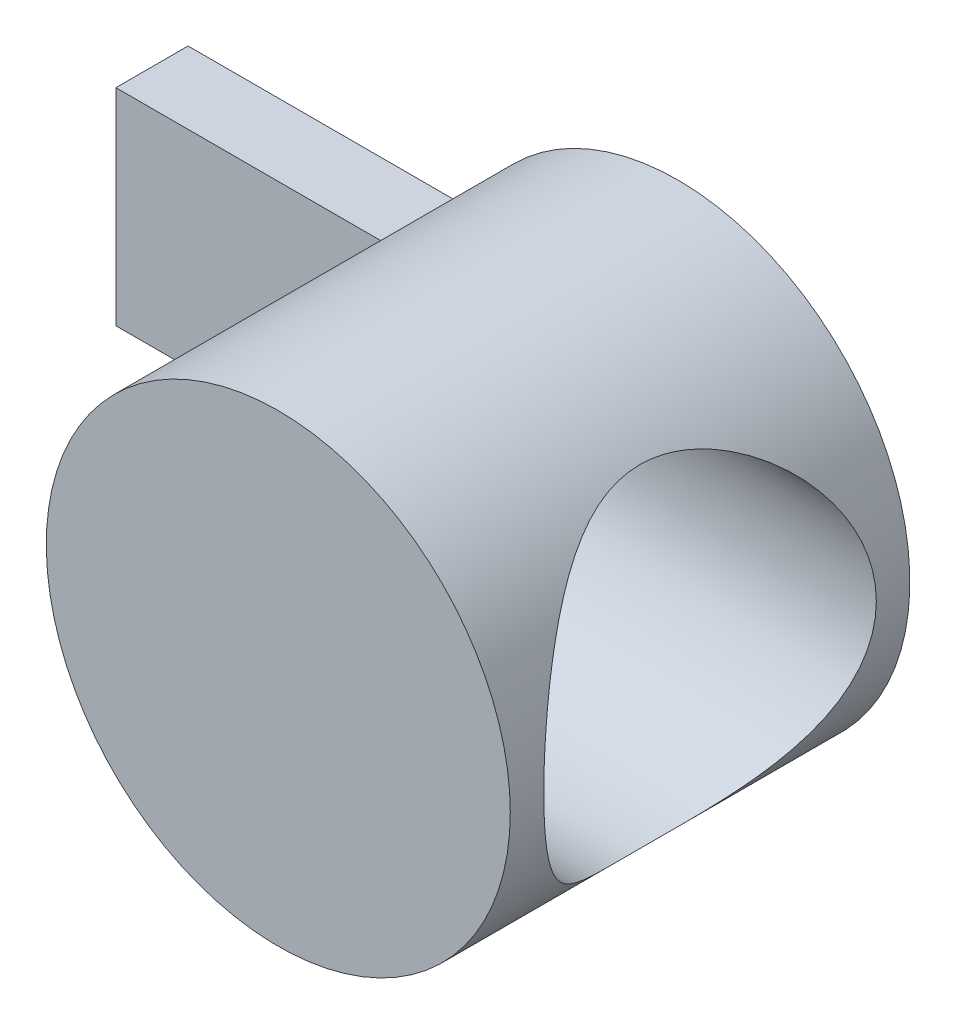
from build123d import *

# Parameters (mm, degrees)
SKETCH_1_R               = 9
EXTRUDE_1_DEPTH          = 15.5
SKETCH_2_W               = 10.937742252
SKETCH_2_H               = 8
EXTRUDE_2_DEPTH          = 2.8
SKETCH_3_R               = 6.45
CUT_EXTRUDE_1_DEPTH      = 10
CUT_EXTRUDE_1_DEPTH_BACK = 2
SKETCH_4_R               = 4
CUT_EXTRUDE_2_DEPTH      = 18


with BuildPart() as part:
    # Эскиз1 → Бобышка-Вытянуть1 (new body)
    with BuildSketch(Plane.XY):
        Circle(SKETCH_1_R)
    extrude(amount=EXTRUDE_1_DEPTH)

    # Эскиз2 → Бобышка-Вытянуть2 (add)
    with BuildSketch(Plane.XY):
        with Locations((-13.531128874, 0)):
            Rectangle(SKETCH_2_W, SKETCH_2_H)
    extrude(amount=EXTRUDE_2_DEPTH)

    # Эскиз3 → Вырез-Вытянуть1 (cut, two sides)
    with BuildSketch(Plane(origin=(0, 0, 0), x_dir=(0, 0, -1), z_dir=(1, 0, 0))) as cut_extrude_1_sk:
        with Locations((-7.75, 0)):
            Circle(SKETCH_3_R)
    extrude(amount=CUT_EXTRUDE_1_DEPTH, mode=Mode.SUBTRACT)
    extrude(cut_extrude_1_sk.sketch, amount=-CUT_EXTRUDE_1_DEPTH_BACK, mode=Mode.SUBTRACT)

    # Эскиз4 → Вырез-Вытянуть2 (cut, through all)
    with BuildSketch(Plane(origin=(-2, 0, 0), x_dir=(0, 0, -1), z_dir=(1, 0, 0))):
        with Locations((-7.75, 0)):
            Circle(SKETCH_4_R)
    extrude(amount=-CUT_EXTRUDE_2_DEPTH, mode=Mode.SUBTRACT)


solid = part.part
